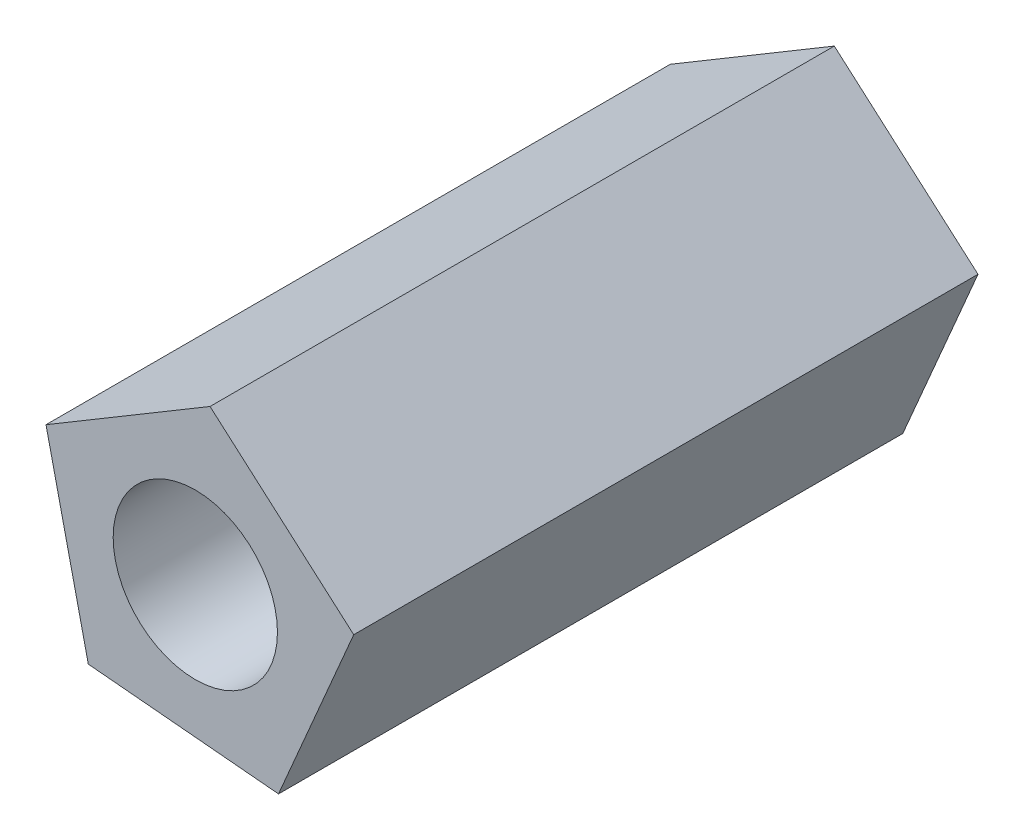
from build123d import *

# Parameters (mm, degrees)
IZIM1_R                     = 2.5
Y_KSEKLIK_EKSTR_ZYON1_DEPTH = 19
SCALE1_SCALE                = 0.5


with BuildPart() as part:
    # Çizim1 → Yükseklik-Ekstrüzyon1 (new body)
    with BuildSketch(Plane.XY):
        Polygon((0.447956651, 4.923937404), (-4.544516536, 1.947612429), (-3.256622333, -3.720246726), (2.531813246, -4.246851352), (4.821368972, 1.095548245), align=None)
        Circle(IZIM1_R, mode=Mode.SUBTRACT)
    extrude(amount=Y_KSEKLIK_EKSTR_ZYON1_DEPTH)


with BuildPart() as part_1:
    # Scale1: scaled about (0, 0, 9.5)
    add(part.part.scale(SCALE1_SCALE).moved(Location((0, 0, 4.75))))


solid = part_1.part
